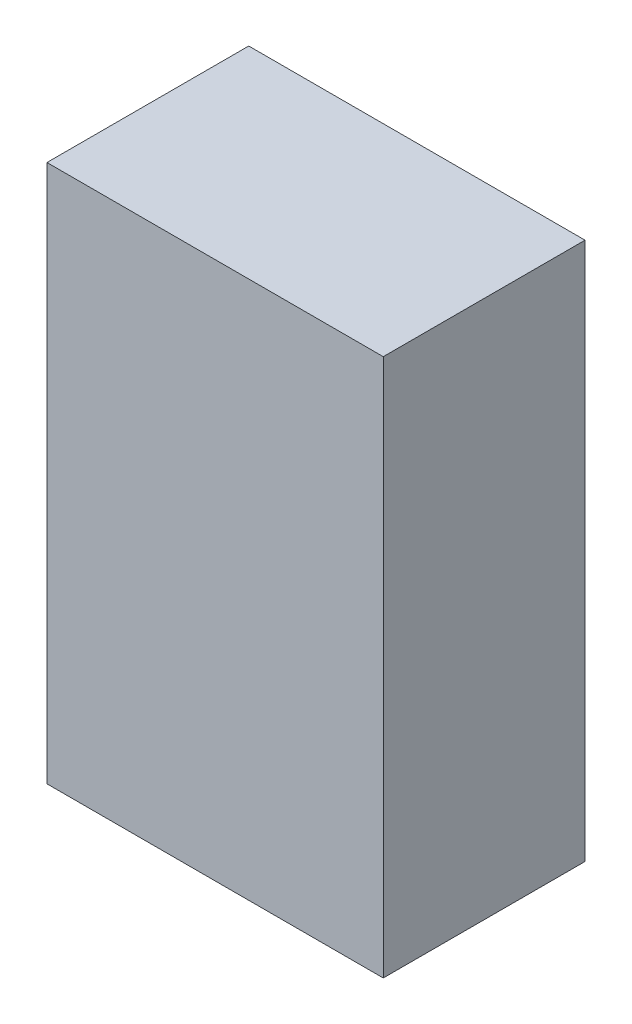
from build123d import *

# Parameters (mm, degrees)
SKETCH1_W           = 5
SKETCH1_H           = 8
BOSS_EXTRUDE1_DEPTH = 1.5


with BuildPart() as part:
    # Sketch1 → Boss-Extrude1 (new body, symmetric)
    with BuildSketch(Plane.XY):
        Rectangle(SKETCH1_W, SKETCH1_H)
    extrude(amount=BOSS_EXTRUDE1_DEPTH, both=True)


solid = part.part
